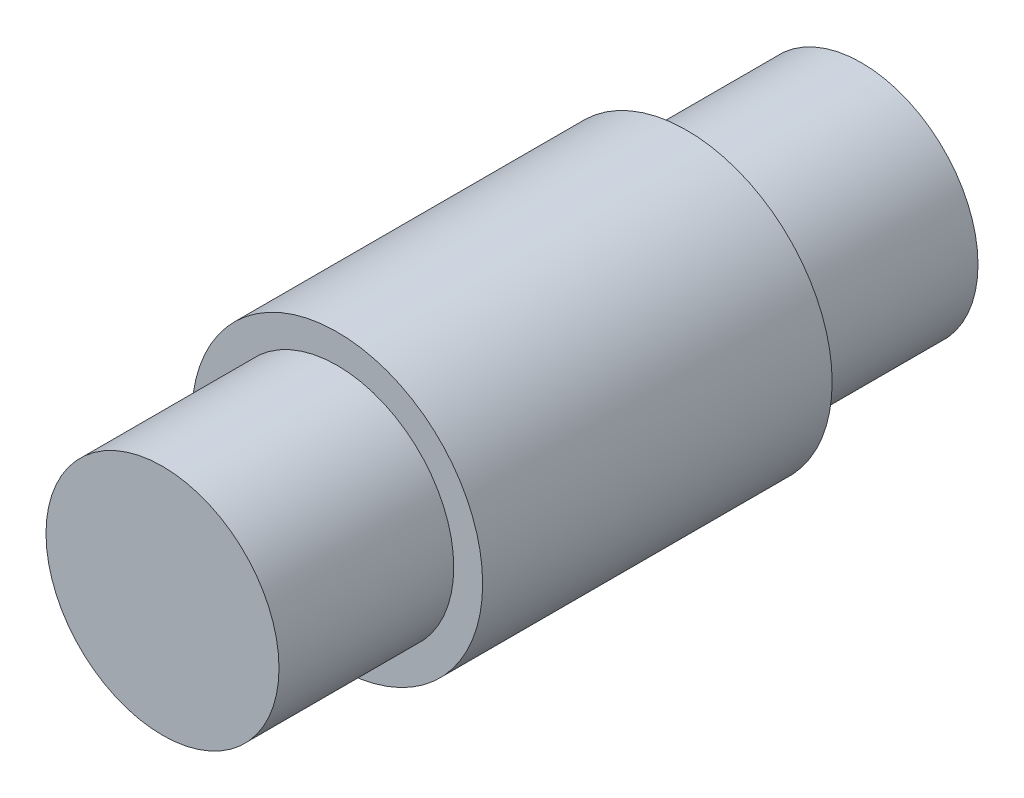
from build123d import *

# Parameters (mm, degrees)
SKETCH1_R           = 3.9624
BOSS_EXTRUDE1_DEPTH = 4.7625
SKETCH2_R           = 3.175
BOSS_EXTRUDE2_DEPTH = 9.525


with BuildPart() as part:
    # Sketch1 → Boss-Extrude1 (new body, symmetric)
    with BuildSketch(Plane.XY):
        Circle(SKETCH1_R)
    extrude(amount=BOSS_EXTRUDE1_DEPTH, both=True)

    # Sketch2 → Boss-Extrude2 (add, symmetric)
    with BuildSketch(Plane.XY):
        Circle(SKETCH2_R)
    extrude(amount=BOSS_EXTRUDE2_DEPTH, both=True)


solid = part.part
